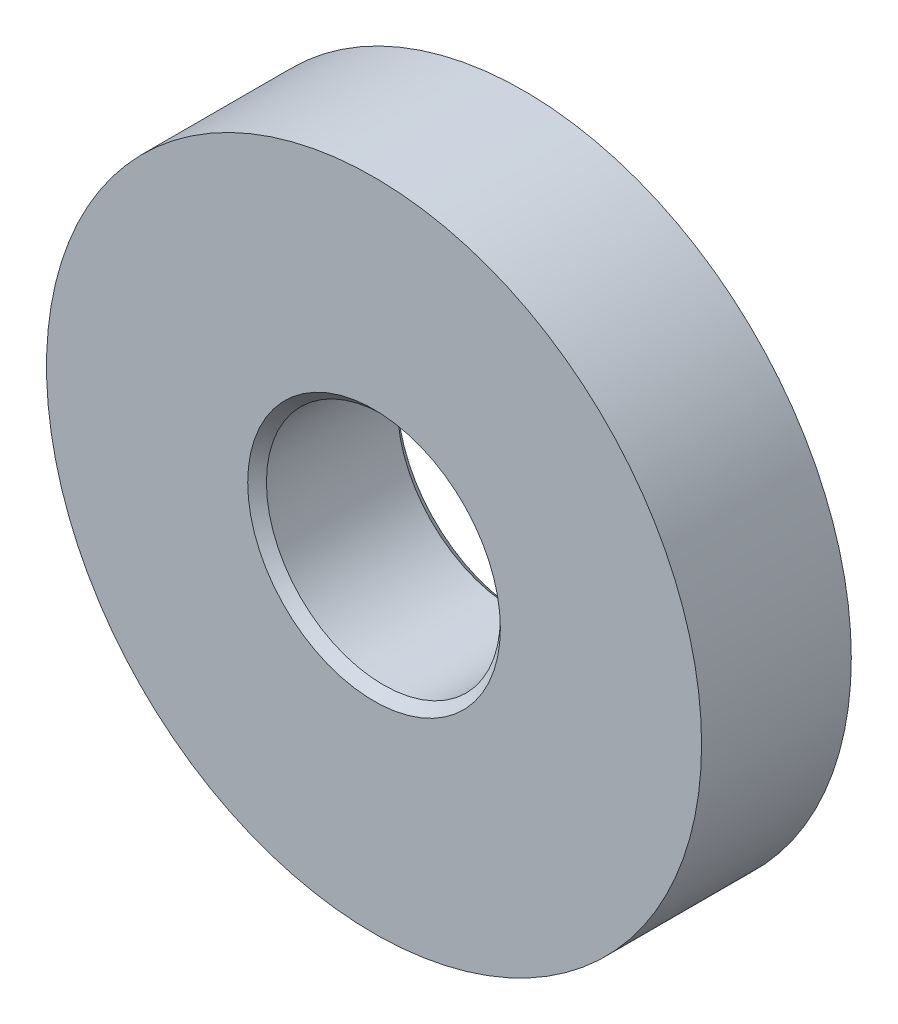
from build123d import *

# Parameters (mm, degrees)
SKETCH1_R           = 3.5
BOSS_EXTRUDE1_DEPTH = 1.6
SKETCH2_R           = 1.25
CUT_EXTRUDE1_DEPTH  = 2.6
CHAMFER1_SIZE       = 0.1


with BuildPart() as part:
    # Sketch1 → Boss-Extrude1 (new body)
    with BuildSketch(Plane.XY):
        Circle(SKETCH1_R)
    extrude(amount=-BOSS_EXTRUDE1_DEPTH)

    # Sketch2 → Cut-Extrude1 (cut, through all)
    with BuildSketch(Plane.XY):
        Circle(SKETCH2_R)
    extrude(amount=-CUT_EXTRUDE1_DEPTH, mode=Mode.SUBTRACT)

    # Chamfer1
    chamfer1_edges = [part.edges().sort_by_distance(p)[0] for p in [
        (-1.25, 0, -1.6),
        (-1.25, 0, 0),
    ]]
    chamfer(chamfer1_edges, length=CHAMFER1_SIZE)


solid = part.part
